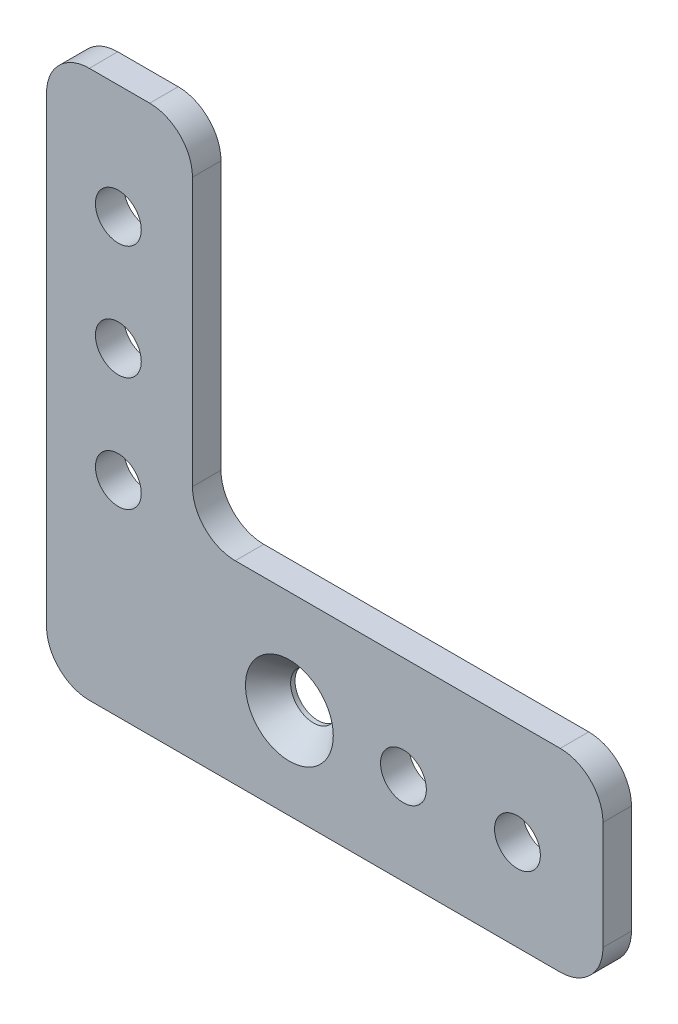
from build123d import *

# Parameters (mm, degrees)
SKETCH1_R           = 2.5527
BOSS_EXTRUDE1_DEPTH = 3.175
FILLET1_R           = 4.7625


with BuildPart() as part:
    # Sketch1 → Boss-Extrude1 (new body)
    with BuildSketch(Plane.XY):
        Polygon((-27.051, 31.75), (-27.051, -29.21), (34.925, -29.21), (34.925, -7.62), (-10.795, -7.62), (-10.795, 31.75), align=None)
        with Locations((-19.05, -19.05)):
            Circle(SKETCH1_R, mode=Mode.SUBTRACT)
        with Locations((-19.05, -6.35)):
            Circle(SKETCH1_R, mode=Mode.SUBTRACT)
        with Locations((12.7, -19.05)):
            Circle(SKETCH1_R, mode=Mode.SUBTRACT)
        with Locations((25.4, -19.05)):
            Circle(SKETCH1_R, mode=Mode.SUBTRACT)
        with Locations((-19.05, 6.35)):
            Circle(SKETCH1_R, mode=Mode.SUBTRACT)
        with Locations((-19.05, 19.05)):
            Circle(SKETCH1_R, mode=Mode.SUBTRACT)
        with Locations((-19.05, -19.05)):
            Circle(SKETCH1_R)
    extrude(amount=BOSS_EXTRUDE1_DEPTH)

    # Fillet1
    fillet1_edges = [part.edges().sort_by_distance(p)[0] for p in [
        (-27.051, 31.75, 1.5875),
        (-10.795, 31.75, 1.5875),
        (-10.795, -7.62, 1.5875),
        (34.925, -7.62, 1.5875),
        (34.925, -29.21, 1.5875),
        (-27.051, -29.21, 1.5875),
    ]]
    fillet(fillet1_edges, radius=FILLET1_R)

    # Sketch2 → CSK for #10 Flat Head Machine Screw1 (revolve, cut)
    with BuildSketch(Plane(origin=(0, -19.05, 3.175), x_dir=(0, -1, 0), z_dir=(1, 0, 0))):
        Polygon((0, 0), (0, 3.175), (2.5527, 3.175), (2.5527, 2.688180894), (4.8895, 0), align=None)
    revolve(axis=Axis((0, -19.05, 9.525), (0, 0, -1)), mode=Mode.SUBTRACT)


solid = part.part
